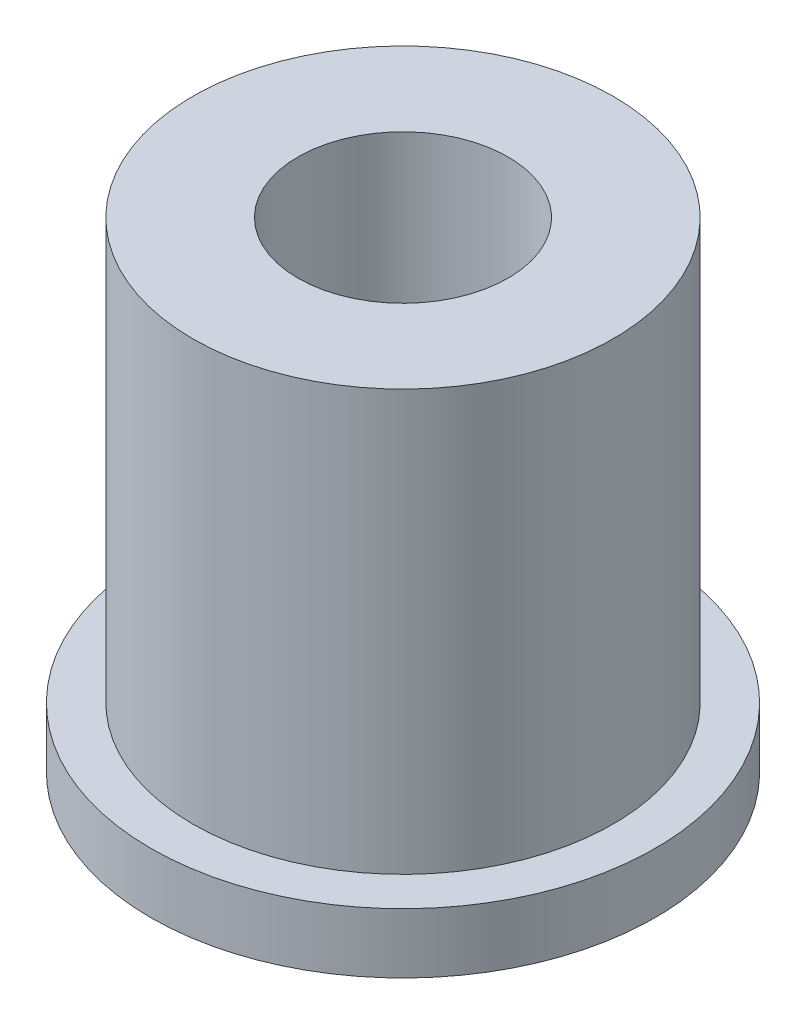
from build123d import *

# Parameters (mm, degrees)
SKETCH1_R           = 21
SKETCH1_R_2         = 8.75
BOSS_EXTRUDE1_DEPTH = 5
SKETCH2_R           = 2.1
SKETCH2_R_2         = 1.6
CUT_EXTRUDE1_DEPTH  = 5
SKETCH3_R           = 17.5
SKETCH3_R_2         = 8.75
BOSS_EXTRUDE2_DEPTH = 35


with BuildPart() as part:
    # Sketch1 → Boss-Extrude1 (new body)
    with BuildSketch(Plane(origin=(0, 0, 0), x_dir=(1, 0, 0), z_dir=(0, 1, 0))):
        Circle(SKETCH1_R)
        Circle(SKETCH1_R_2, mode=Mode.SUBTRACT)
    extrude(amount=BOSS_EXTRUDE1_DEPTH)

    # Sketch2 → Cut-Extrude1 (cut)
    with BuildSketch(Plane.XZ):
        with Locations((-10.253048327, 10.253048327)):
            Circle(SKETCH2_R)
        with Locations((10.253048327, -10.253048327)):
            Circle(SKETCH2_R)
        with Locations((-15, 0)):
            Circle(SKETCH2_R_2)
        with Locations((7.5, 12.990381057)):
            Circle(SKETCH2_R_2)
        with Locations((7.5, -12.990381057)):
            Circle(SKETCH2_R_2)
        with Locations((8.838834765, 8.838834765)):
            Circle(SKETCH2_R_2)
        with Locations((-8.838834765, -8.838834765)):
            Circle(SKETCH2_R_2)
    extrude(amount=-CUT_EXTRUDE1_DEPTH, mode=Mode.SUBTRACT)

    # Sketch3 → Boss-Extrude2 (add)
    with BuildSketch(Plane(origin=(0, 5, 0), x_dir=(1, 0, 0), z_dir=(0, 1, 0))):
        Circle(SKETCH3_R)
        Circle(SKETCH3_R_2, mode=Mode.SUBTRACT)
    extrude(amount=BOSS_EXTRUDE2_DEPTH)


solid = part.part
